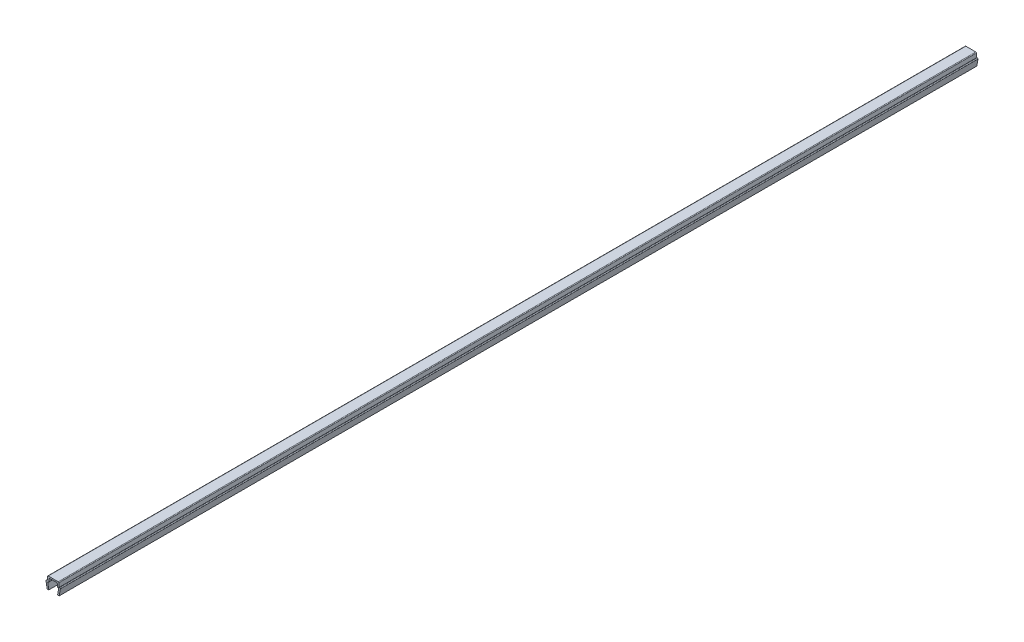
from build123d import *

# Parameters (mm, degrees)
BOSS_EXTRUDE1_DEPTH = 230


with BuildPart() as part:
    # Sketch1 → Boss-Extrude1 (new body, symmetric)
    with BuildSketch(Plane.XY):
        with BuildLine():
            Line((-3.6, 3.35), (-3, 0))
            Line((-3, 0), (-2.2, 0))
            Line((-2.2, 0), (-2.735217071, 2.988295315))
            ThreePointArc((-2.735217071, 2.988295315), (-2.659117427, 3.274614514), (-2.390699246, 3.4))
            Line((-2.390699246, 3.4), (-2.2, 3.4))
            Line((-2.2, 3.4), (-2.070472639, 4.88050451))
            ThreePointArc((-2.070472639, 4.88050451), (-1.958261067, 5.108047068), (-1.721804495, 5.2))
            Line((-1.721804495, 5.2), (1.721804495, 5.2))
            ThreePointArc((1.721804495, 5.2), (1.958261067, 5.108047068), (2.070472639, 4.88050451))
            Line((2.070472639, 4.88050451), (2.2, 3.4))
            Line((2.2, 3.4), (2.390699246, 3.4))
            ThreePointArc((2.390699246, 3.4), (2.659117427, 3.274614514), (2.735217071, 2.988295315))
            Line((2.735217071, 2.988295315), (2.2, 0))
            Line((2.2, 0), (3, 0))
            Line((3, 0), (3.6, 3.35))
            ThreePointArc((3.6, 3.35), (3.497487373, 3.597487373), (3.25, 3.7))
            Line((3.25, 3.7), (3, 3.7))
            Line((3, 3.7), (2.835477174, 5.58050451))
            ThreePointArc((2.835477174, 5.58050451), (2.723265602, 5.808047068), (2.486809029, 5.9))
            Line((2.486809029, 5.9), (-2.486809029, 5.9))
            ThreePointArc((-2.486809029, 5.9), (-2.723265602, 5.808047068), (-2.835477174, 5.58050451))
            Line((-2.835477174, 5.58050451), (-3, 3.7))
            Line((-3, 3.7), (-3.25, 3.7))
            ThreePointArc((-3.25, 3.7), (-3.497487373, 3.597487373), (-3.6, 3.35))
        make_face()
    extrude(amount=BOSS_EXTRUDE1_DEPTH, both=True)


solid = part.part
